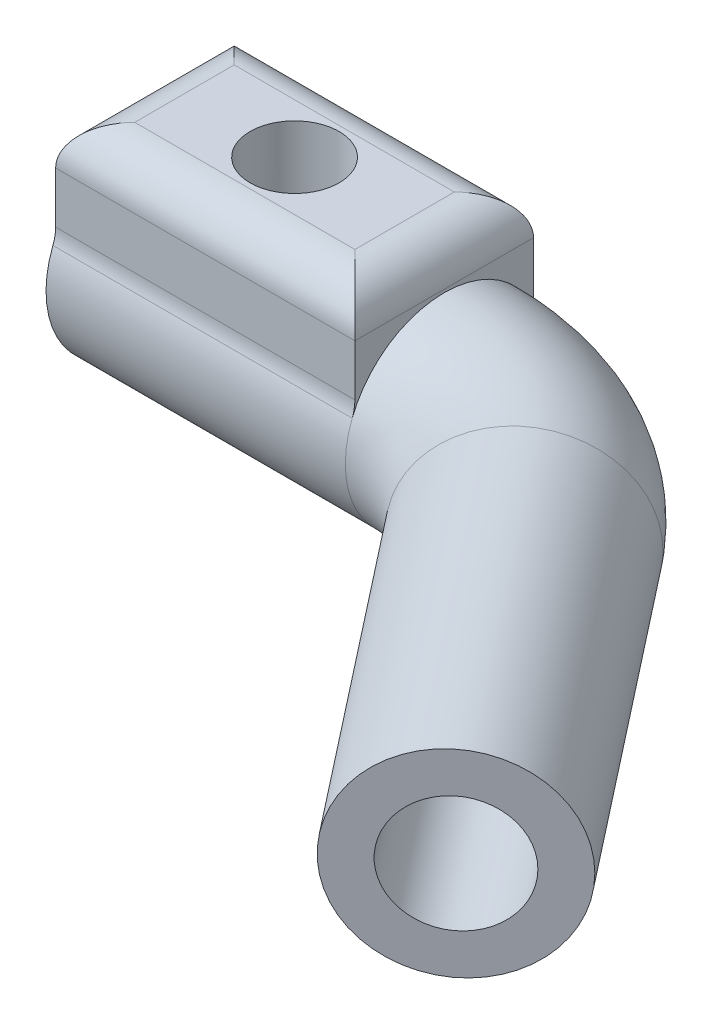
from build123d import *

# Parameters (mm, degrees)
SKETCH2_R           = 5
CUT_EXTRUDE1_DEPTH  = 12.5
SKETCH5_R           = 2.95
CUT_EXTRUDE3_DEPTH  = 10
SKETCH14_W          = 15.128379637
SKETCH14_H          = 10
CUT_EXTRUDE4_DEPTH  = 5
SKETCH15_W          = 15.128379637
SKETCH15_H          = 9.028288874
BOSS_EXTRUDE3_DEPTH = 5
FILLET2_R           = 2
FILLET3_R           = 2
CUT_EXTRUDE5_REACH  = 14.15
SKETCH16_R          = 2.25


with BuildPart() as part:
    # Sweep1: sweep along a path in Sketch1
    with BuildLine(Plane(origin=(0, 0, 0), x_dir=(1, 0, 0), z_dir=(0, 1, 0))) as sweep1_path:
        Line((0, 0), (15.128379637, 0))
        ThreePointArc((15.128379637, 0), (19.50794708, -1.010039543), (23.002807262, -3.836122196))
        Line((23.002807262, -3.836122196), (35.409694509, -19.686069062))
    # Sketch2 → Sweep1 (sweep)
    with BuildSketch(Plane(origin=(0, 0, 0), x_dir=(0, 0, -1), z_dir=(1, 0, 0))):
        Circle(SKETCH2_R)
    sweep(path=sweep1_path.line)

    # Sketch4 → Cut-Extrude1 (cut)
    with BuildSketch(Plane.ZY):
        with BuildLine():
            Line((-2.163330765, 2.15), (2.163330765, 2.15))
            ThreePointArc((2.163330765, 2.15), (0, -3.05), (-2.163330765, 2.15))
        make_face()
    extrude(amount=-CUT_EXTRUDE1_DEPTH, mode=Mode.SUBTRACT)

    # Sketch5 → Cut-Extrude3 (cut)
    with BuildSketch(Plane(origin=(23.008372425, 0, 29.393470993), x_dir=(0.787442762, 0, -0.61638778), z_dir=(0.61638778, 0, 0.787442762))):
        with Locations((15.74885525, 0)):
            Circle(SKETCH5_R)
    extrude(amount=-CUT_EXTRUDE3_DEPTH, mode=Mode.SUBTRACT)

    # Sketch14 → Cut-Extrude4 (cut)
    with BuildSketch(Plane.XZ.offset(-2.15)):
        with Locations((7.564189819, 0)):
            Rectangle(SKETCH14_W, SKETCH14_H)
    extrude(amount=-CUT_EXTRUDE4_DEPTH, mode=Mode.SUBTRACT)

    # Sketch15 → Boss-Extrude3 (add)
    with BuildSketch(Plane(origin=(0, 2.15, 0), x_dir=(1, 0, 0), z_dir=(0, 1, 0))):
        with Locations((7.564189819, 0)):
            Rectangle(SKETCH15_W, SKETCH15_H)
    extrude(amount=BOSS_EXTRUDE3_DEPTH)

    # Fillet2
    fillet2_edges = [part.edges().sort_by_distance(p)[0] for p in [
        (7.564189819, 2.15, -4.514144437),
        (7.564189819, 2.15, 4.514144437),
    ]]
    fillet(fillet2_edges, radius=FILLET2_R)

    # Fillet3
    fillet3_edges = [part.edges().sort_by_distance(p)[0] for p in [
        (0, 7.15, 0),
        (7.564189819, 7.15, 4.514144437),
        (15.128379637, 7.15, 0),
        (7.564189819, 7.15, -4.514144437),
    ]]
    fillet(fillet3_edges, radius=FILLET3_R)

    # Sketch16 → Cut-Extrude5 (cut, up to next)
    with BuildSketch(Plane(origin=(0, 7.15, 0), x_dir=(1, 0, 0), z_dir=(0, 1, 0)), mode=Mode.PRIVATE) as cut_extrude5_sk1:
        with Locations((7.564189819, 0)):
            Circle(SKETCH16_R)
    cut_extrude5_tool1 = extrude(cut_extrude5_sk1.sketch, amount=-CUT_EXTRUDE5_REACH, mode=Mode.PRIVATE) & part.part
    add(cut_extrude5_tool1.solids().sort_by_distance((7.56419, 7.15, 0))[0], mode=Mode.SUBTRACT)


solid = part.part
